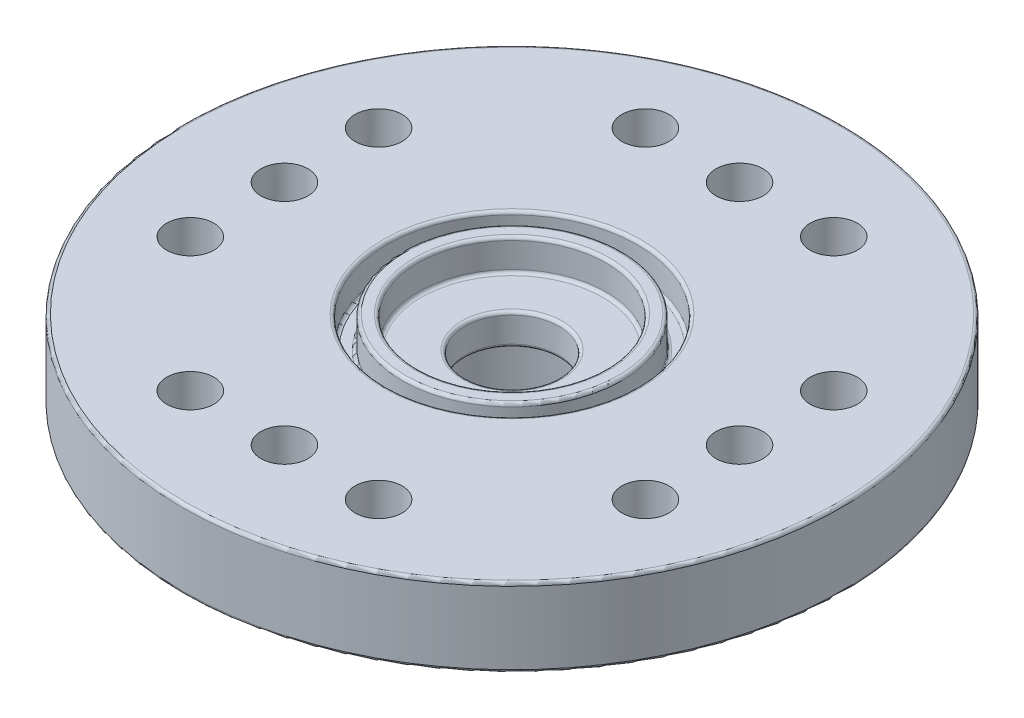
from build123d import *

# Parameters (mm, degrees)
SKETCH_1_R          = 10.5
EXTRUDE_1_DEPTH     = 2.5
SKETCH_2_R          = 3
CUT_EXTRUDE_1_DEPTH = 12
SKETCH_3_R          = 4
SKETCH_3_R_2        = 3
EXTRUDE_2_DEPTH     = 3
SKETCH_4_R          = 0.75
CUT_EXTRUDE_2_DEPTH = 3
SKETCH_5_R          = 3
EXTRUDE_3_DEPTH     = 2
SKETCH_6_R          = 3
CUT_EXTRUDE_3_DEPTH = 1
SKETCH_7_R          = 1.5
CUT_EXTRUDE_5_DEPTH = 1
SKETCH_8_R          = 4
SKETCH_8_R_2        = 3.5
CUT_EXTRUDE_6_DEPTH = 1
FILLET_1_R          = 0.1


with BuildPart() as part:
    # 草图1 → 凸台-拉伸1 (new body)
    with BuildSketch(Plane(origin=(0, 0, 0), x_dir=(1, 0, 0), z_dir=(0, 1, 0))):
        Circle(SKETCH_1_R)
    extrude(amount=EXTRUDE_1_DEPTH)

    # 草图2 → 切除-拉伸1 (cut)
    with BuildSketch(Plane(origin=(0, 2.5, 0), x_dir=(1, 0, 0), z_dir=(0, 1, 0))):
        Circle(SKETCH_2_R)
    extrude(amount=-CUT_EXTRUDE_1_DEPTH, mode=Mode.SUBTRACT)

    # 草图3 → 凸台-拉伸2 (add)
    with BuildSketch(Plane.XZ):
        Circle(SKETCH_3_R)
        Circle(SKETCH_3_R_2, mode=Mode.SUBTRACT)
    extrude(amount=EXTRUDE_2_DEPTH)

    # 草图4 → 切除-拉伸2 (cut)
    with BuildSketch(Plane(origin=(0, 2.5, 0), x_dir=(1, 0, 0), z_dir=(0, 1, 0))):
        with Locations((0, 7.25)):
            Circle(SKETCH_4_R)
        with Locations((7.25, 0)):
            Circle(SKETCH_4_R)
        with Locations((3, 7.25)):
            Circle(SKETCH_4_R)
        with Locations((7.25, 3)):
            Circle(SKETCH_4_R)
        with Locations((-3, 7.25)):
            Circle(SKETCH_4_R)
        with Locations((7.25, -3)):
            Circle(SKETCH_4_R)
        with Locations((3, -7.25)):
            Circle(SKETCH_4_R)
        with Locations((0, -7.25)):
            Circle(SKETCH_4_R)
        with Locations((-3, -7.25)):
            Circle(SKETCH_4_R)
        with Locations((-7.25, -3)):
            Circle(SKETCH_4_R)
        with Locations((-7.25, 0)):
            Circle(SKETCH_4_R)
        with Locations((-7.25, 3)):
            Circle(SKETCH_4_R)
    extrude(amount=-CUT_EXTRUDE_2_DEPTH, mode=Mode.SUBTRACT)

    # 草图5 → 凸台-拉伸3 (add)
    with BuildSketch(Plane(origin=(0, 2.5, 0), x_dir=(1, 0, 0), z_dir=(0, 1, 0))):
        Circle(SKETCH_5_R)
    extrude(amount=-EXTRUDE_3_DEPTH)

    # 草图6 → 切除-拉伸3 (cut)
    with BuildSketch(Plane(origin=(0, 2.5, 0), x_dir=(1, 0, 0), z_dir=(0, 1, 0))):
        Circle(SKETCH_6_R)
    extrude(amount=-CUT_EXTRUDE_3_DEPTH, mode=Mode.SUBTRACT)

    # 草图7 → 切除-拉伸5 (cut)
    with BuildSketch(Plane(origin=(0, 1.5, 0), x_dir=(1, 0, 0), z_dir=(0, 1, 0))):
        Circle(SKETCH_7_R)
    extrude(amount=-CUT_EXTRUDE_5_DEPTH, mode=Mode.SUBTRACT)

    # 草图8 → 切除-拉伸6 (cut)
    with BuildSketch(Plane(origin=(0, 2.5, 0), x_dir=(1, 0, 0), z_dir=(0, 1, 0))):
        Circle(SKETCH_8_R)
        Circle(SKETCH_8_R_2, mode=Mode.SUBTRACT)
    extrude(amount=-CUT_EXTRUDE_6_DEPTH, mode=Mode.SUBTRACT)

    # 圆角1
    fillet_1_edges = [part.edges().sort_by_distance(p)[0] for p in [
        (-4, -3, 0),
        (-3, -3, 0),
        (-10.5, 0, 0),
        (-10.5, 2.5, 0),
        (-3, 1.5, 0),
        (-3, 2.5, 0),
        (-1.5, 0.5, 0),
        (-1.5, 1.5, 0),
        (-4, 1.5, 0),
        (-3.5, 1.5, 0),
        (-4, 2.5, 0),
        (-3.5, 2.5, 0),
    ]]
    fillet(fillet_1_edges, radius=FILLET_1_R)


solid = part.part
